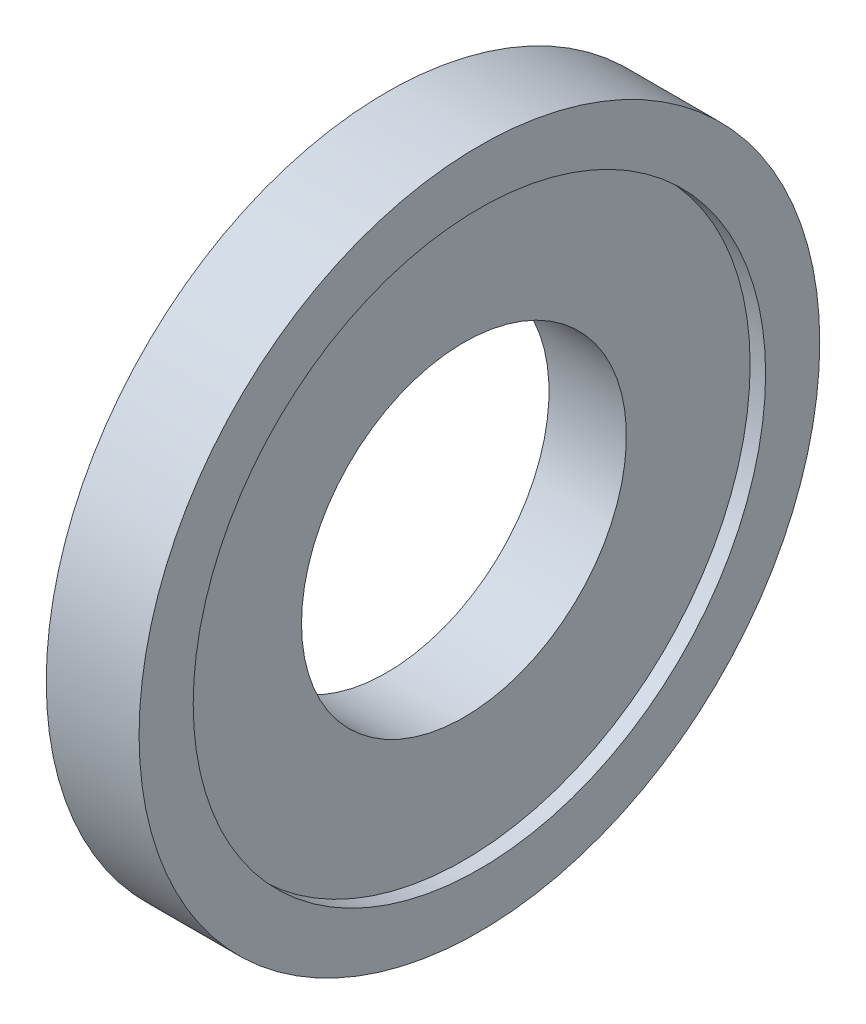
from build123d import *


with BuildPart() as part:
    # 草图1 → 旋转1 (revolve)
    with BuildSketch(Plane.XY):
        Polygon((0, 5.25), (0, 11), (3, 11), (3, 9.25), (2.5, 9.25), (2.5, 5.25), align=None)
    revolve(axis=Axis((0, 0, 0), (1, 0, 0)))


solid = part.part
